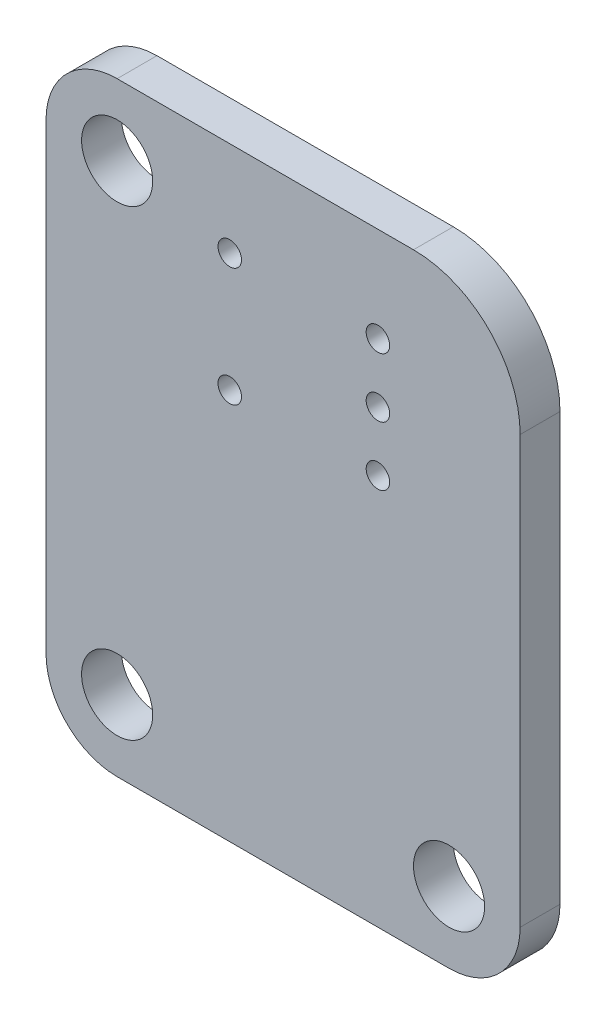
from build123d import *

# Parameters (mm, degrees)
BOARD_DEPTH        = 1.68
SKETCH2_R          = 1.5
SKETCH2_R_2        = 0.4953
PLATED_HOLES_DEPTH = 5.7


with BuildPart() as part:
    # Sketch1 → BOARD (new body)
    with BuildSketch(Plane.XY.offset(-4.7)):
        with BuildLine():
            Line((100, 42.5), (100, 60.5))
            ThreePointArc((100, 60.5), (98.681980515, 63.681980515), (95.5, 65))
            Line((95.5, 65), (83, 65))
            ThreePointArc((83, 65), (80.878679656, 64.121320344), (80, 62))
            Line((80, 62), (80, 42.5))
            ThreePointArc((80, 42.5), (80.878679656, 40.378679656), (83, 39.5))
            Line((83, 39.5), (97, 39.5))
            ThreePointArc((97, 39.5), (99.121320344, 40.378679656), (100, 42.5))
        make_face()
    extrude(amount=BOARD_DEPTH)

    # Sketch2 → PLATED HOLES (cut, through all)
    with BuildSketch(Plane.XY):
        with Locations((83, 42.5)):
            Circle(SKETCH2_R)
        with Locations((97, 42.5)):
            Circle(SKETCH2_R)
        with Locations((97, 35.5)):
            Circle(SKETCH2_R)
        with Locations((83, 62)):
            Circle(SKETCH2_R)
        with Locations((87.749999989, 55.999999989)):
            Circle(SKETCH2_R_2)
        with Locations((87.749999989, 60.999999996)):
            Circle(SKETCH2_R_2)
        with Locations((94.000000011, 58.499999992)):
            Circle(SKETCH2_R_2)
        with Locations((94.000000011, 55.999999989)):
            Circle(SKETCH2_R_2)
        with Locations((94.000000011, 60.999999996)):
            Circle(SKETCH2_R_2)
    extrude(amount=-PLATED_HOLES_DEPTH, mode=Mode.SUBTRACT)


solid = part.part
